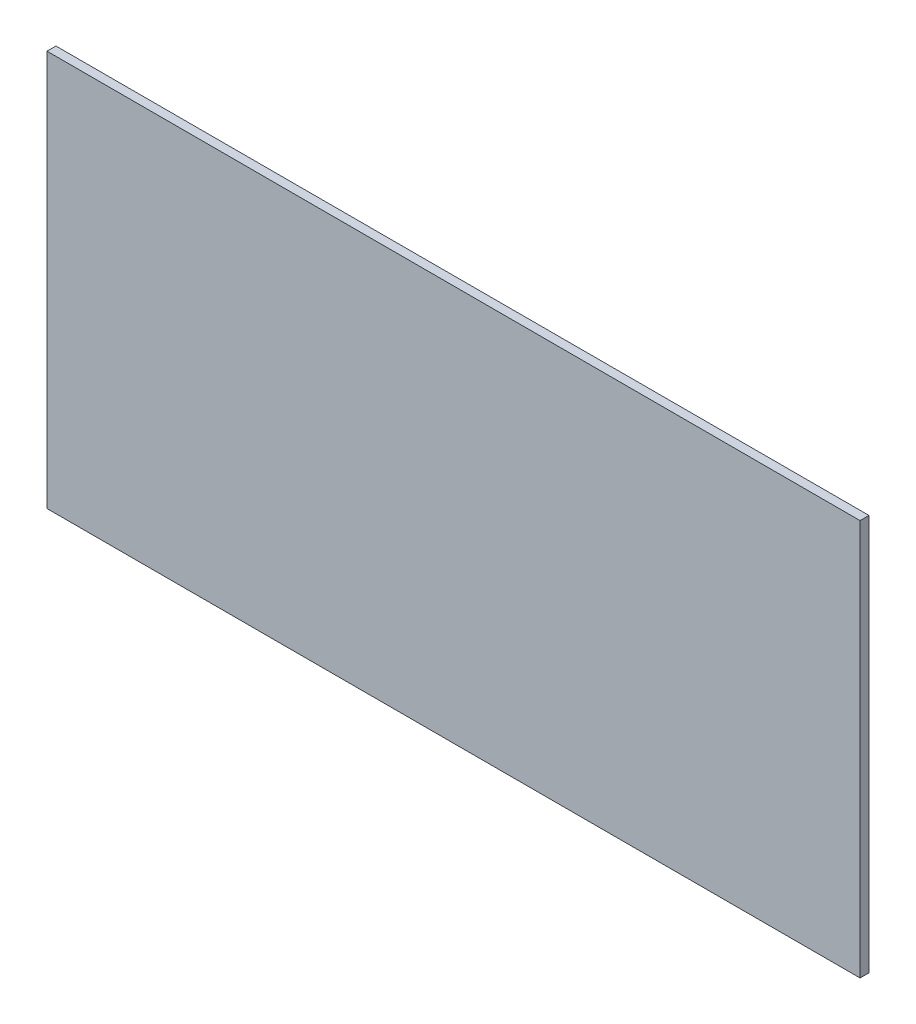
from build123d import *

# Parameters (mm, degrees)
ESQUISSE1_W        = 273
ESQUISSE1_H        = 133
BOSS_EXTRU_1_DEPTH = 3


with BuildPart() as part:
    # Esquisse1 → Boss.-Extru.1 (new body)
    with BuildSketch(Plane.XY):
        with Locations((98.424323811, -37.469926441)):
            Rectangle(ESQUISSE1_W, ESQUISSE1_H)
    extrude(amount=BOSS_EXTRU_1_DEPTH)


solid = part.part
